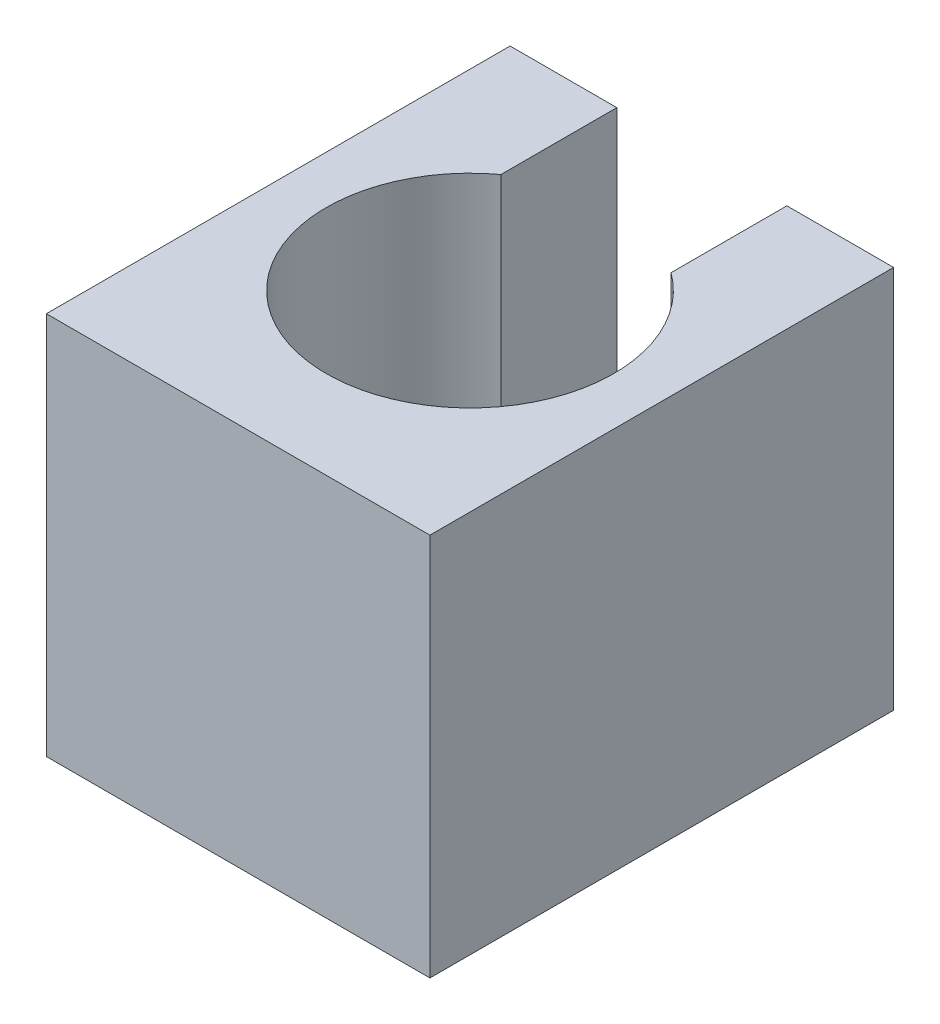
from build123d import *

# Parameters (mm, degrees)
EXTRUDE_1_DEPTH = 6


with BuildPart() as part:
    # Эскиз1 → Бобышка-Вытянуть1 (new body)
    with BuildSketch(Plane(origin=(0, 0, 0), x_dir=(1, 0, 0), z_dir=(0, 1, 0))):
        with BuildLine():
            Line((-3, 3.627046628), (-1.330273321, 3.627046628))
            Line((-1.330273321, 3.627046628), (-1.330273321, 1.81462748))
            ThreePointArc((-1.330273321, 1.81462748), (0, -2.25), (1.330273321, 1.81462748))
            Line((1.330273321, 1.81462748), (1.330273321, 3.627046628))
            Line((1.330273321, 3.627046628), (3, 3.627046628))
            Line((3, 3.627046628), (3, -3.627046628))
            Line((3, -3.627046628), (-3, -3.627046628))
            Line((-3, -3.627046628), (-3, 3.627046628))
        make_face()
    extrude(amount=EXTRUDE_1_DEPTH)


solid = part.part
